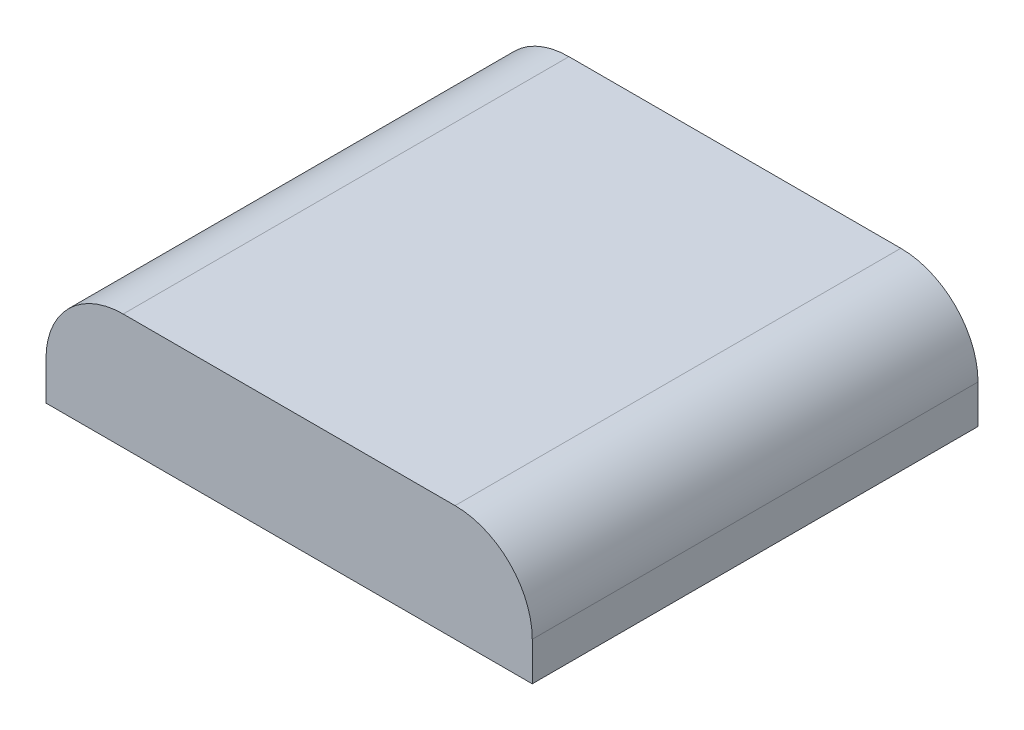
from build123d import *

# Parameters (mm, degrees)
SKETCH1_W           = 63
SKETCH1_H           = 57.75
BOSS_EXTRUDE1_DEPTH = 15
FILLET1_R           = 10


with BuildPart() as part:
    # Sketch1 → Boss-Extrude1 (new body)
    with BuildSketch(Plane(origin=(0, 0, 0), x_dir=(1, 0, 0), z_dir=(0, 1, 0))):
        Rectangle(SKETCH1_W, SKETCH1_H)
    extrude(amount=BOSS_EXTRUDE1_DEPTH)

    # Fillet1
    fillet1_edges = [part.edges().sort_by_distance(p)[0] for p in [
        (-31.5, 15, 0),
        (31.5, 15, 0),
    ]]
    fillet(fillet1_edges, radius=FILLET1_R)


solid = part.part
